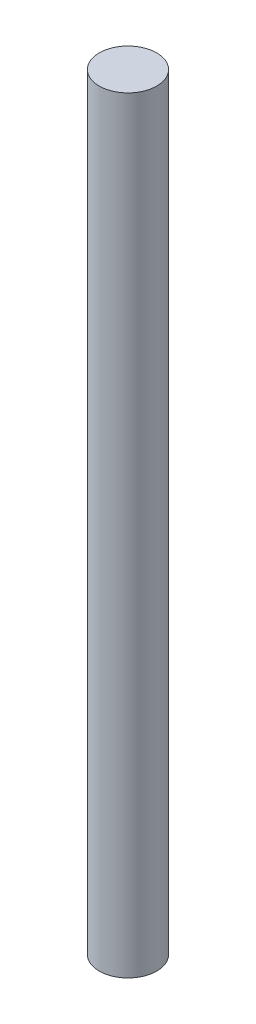
from build123d import *

# Parameters (mm, degrees)
SKETCH1_R           = 6
BOSS_EXTRUDE1_DEPTH = 160


with BuildPart() as part:
    # Sketch1 → Boss-Extrude1 (new body)
    with BuildSketch(Plane(origin=(0, 0, 0), x_dir=(1, 0, 0), z_dir=(0, 1, 0))):
        Circle(SKETCH1_R)
    extrude(amount=BOSS_EXTRUDE1_DEPTH)


solid = part.part
